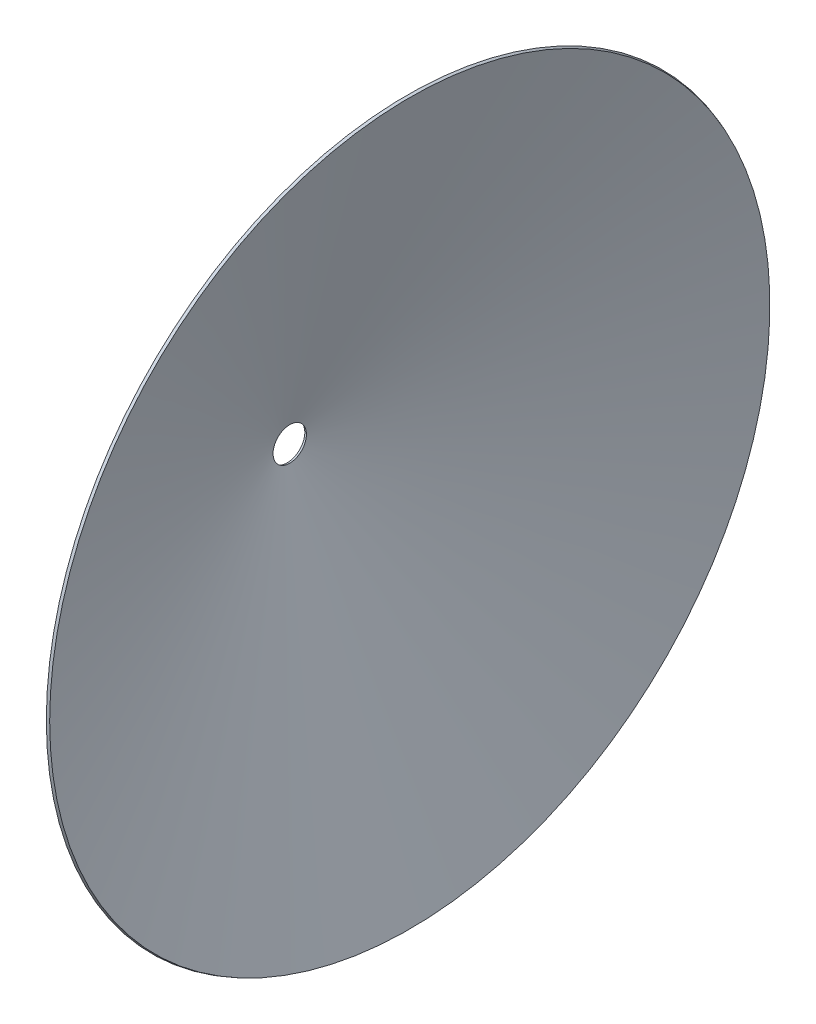
from build123d import *


with BuildPart() as part:
    # Sketch1 → Revolve-Thin1 (revolve)
    with BuildSketch(Plane(origin=(0, 0, 0), x_dir=(1, 0, 0), z_dir=(0, 1, 0))):
        Polygon((0, 248.916154258), (457.2, -1059.183845742), (447.759988468, -1062.483267248), (-9.440011532, 245.616732752), align=None)
    revolve(axis=Axis((0, 0, -312.416154258), (1, 0, 0)))


solid = part.part
